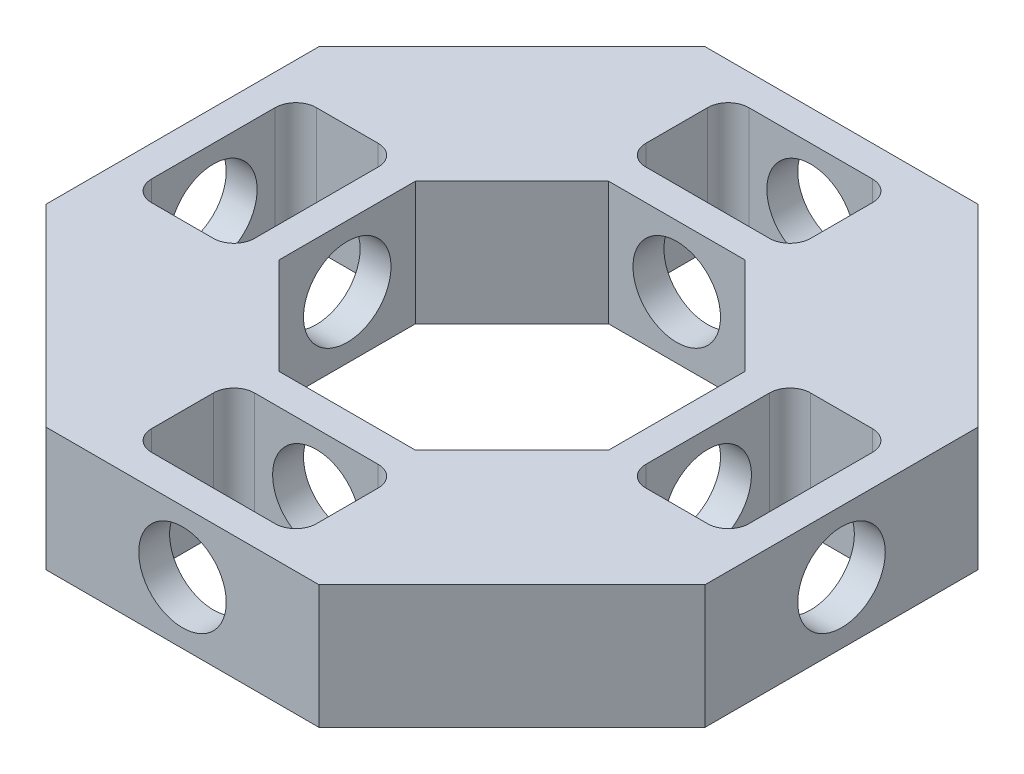
from build123d import *

# Parameters (mm, degrees)
BOSS_EXTRUDE1_DEPTH = 19.05
CUT_EXTRUDE1_DEPTH  = 75.324844433
CIRPATTERN1_COUNT   = 4


with BuildPart() as part:
    # Sketch1 → Boss-Extrude1 (new body)
    with BuildSketch(Plane(origin=(0, 0, 0), x_dir=(1, 0, 0), z_dir=(0, 1, 0))):
        Polygon((-50.8, -21.042048969), (-50.8, 21.042048969), (-21.042048969, 50.8), (21.042048969, 50.8), (50.8, 21.042048969), (50.8, -21.042048969), (21.042048969, -50.8), (-21.042048969, -50.8), align=None)
        Polygon((-25.4, 10.521024484), (-10.521024484, 25.4), (10.521024484, 25.4), (25.4, 10.521024484), (25.4, -10.521024484), (10.521024484, -25.4), (-10.521024484, -25.4), (-25.4, -10.521024484), align=None, mode=Mode.SUBTRACT)
    extrude(amount=BOSS_EXTRUDE1_DEPTH)

    # Sketch2 → Cut-Extrude1 (cut, through all)
    with BuildSketch(Plane(origin=(0, 19.05, 0), x_dir=(1, 0, 0), z_dir=(0, 1, 0))):
        with BuildLine():
            Line((33.3375, 12.7), (42.8625, 12.7))
            ThreePointArc((42.8625, 12.7), (45.10756403, 11.77006403), (46.0375, 9.525))
            Line((46.0375, 9.525), (46.0375, -9.525))
            ThreePointArc((46.0375, -9.525), (45.10756403, -11.77006403), (42.8625, -12.7))
            Line((42.8625, -12.7), (33.3375, -12.7))
            ThreePointArc((33.3375, -12.7), (31.09243597, -11.77006403), (30.1625, -9.525))
            Line((30.1625, -9.525), (30.1625, 9.525))
            ThreePointArc((30.1625, 9.525), (31.09243597, 11.77006403), (33.3375, 12.7))
        make_face()
    cut_extrude1 = extrude(amount=-CUT_EXTRUDE1_DEPTH, mode=Mode.SUBTRACT)

    # Sketch4 → 1_2 Clearance Hole1 (revolve, cut)
    with BuildSketch(Plane(origin=(50.8, 9.525, 0), x_dir=(0, 0, -1), z_dir=(0, 1, 0))):
        Polygon((0, 0), (0, 67.553549943), (6.74624, 63.5), (6.74624, 0), align=None)
    f_1_2_clearance_hole1 = revolve(axis=Axis((57.15, 9.525, 0), (-1, 0, 0)), mode=Mode.SUBTRACT)

    # CirPattern1: Cut-Extrude1, 1_2 Clearance Hole1 ×4 about axis
    cirpattern1_axis = Axis((0, -0.9525, 0), (0, 1, 0))
    add([cut_extrude1.rotate(cirpattern1_axis, i * 360 / CIRPATTERN1_COUNT) for i in range(1, CIRPATTERN1_COUNT)], mode=Mode.SUBTRACT)
    add([f_1_2_clearance_hole1.rotate(cirpattern1_axis, i * 360 / CIRPATTERN1_COUNT) for i in range(1, CIRPATTERN1_COUNT)], mode=Mode.SUBTRACT)


solid = part.part
